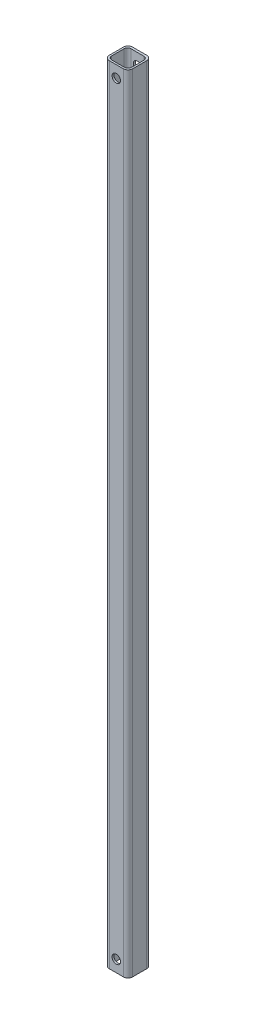
from build123d import *

# Parameters (mm, degrees)
BOSS_EXTRUDE1_DEPTH = 533.4
SKETCH2_R           = 5.715
CUT_EXTRUDE1_DEPTH  = 32.75


with BuildPart() as part:
    # Sketch1 → Boss-Extrude1 (new body, symmetric)
    with BuildSketch(Plane(origin=(0, 0, 0), x_dir=(1, 0, 0), z_dir=(0, 1, 0))):
        with BuildLine():
            Line((-9.525, -15.875), (9.525, -15.875))
            ThreePointArc((9.525, -15.875), (14.015128061, -14.015128061), (15.875, -9.525))
            Line((15.875, -9.525), (15.875, 9.525))
            ThreePointArc((15.875, 9.525), (14.015128061, 14.015128061), (9.525, 15.875))
            Line((9.525, 15.875), (-9.525, 15.875))
            ThreePointArc((-9.525, 15.875), (-14.015128061, 14.015128061), (-15.875, 9.525))
            Line((-15.875, 9.525), (-15.875, -9.525))
            ThreePointArc((-15.875, -9.525), (-14.015128061, -14.015128061), (-9.525, -15.875))
        make_face()
        with BuildLine():
            Line((-8.6995, -13.462), (8.6995, -13.462))
            ThreePointArc((8.6995, -13.462), (12.067096045, -12.067096045), (13.462, -8.6995))
            Line((13.462, -8.6995), (13.462, 8.0645))
            ThreePointArc((13.462, 8.0645), (12.067096045, 11.432096045), (8.6995, 12.827))
            Line((8.6995, 12.827), (-8.6995, 12.827))
            ThreePointArc((-8.6995, 12.827), (-12.067096045, 11.432096045), (-13.462, 8.0645))
            Line((-13.462, 8.0645), (-13.462, -8.6995))
            ThreePointArc((-13.462, -8.6995), (-12.067096045, -12.067096045), (-8.6995, -13.462))
        make_face(mode=Mode.SUBTRACT)
    extrude(amount=BOSS_EXTRUDE1_DEPTH, both=True)

    # Sketch2 → Cut-Extrude1 (cut, through all)
    with BuildSketch(Plane.XY.offset(15.875)):
        with Locations((0, 517.525)):
            Circle(SKETCH2_R)
    cut_extrude1 = extrude(amount=-CUT_EXTRUDE1_DEPTH, mode=Mode.SUBTRACT)

    # Mirror1: Cut-Extrude1 across plane
    add(cut_extrude1.mirror(Plane.ZX), mode=Mode.SUBTRACT)


solid = part.part
